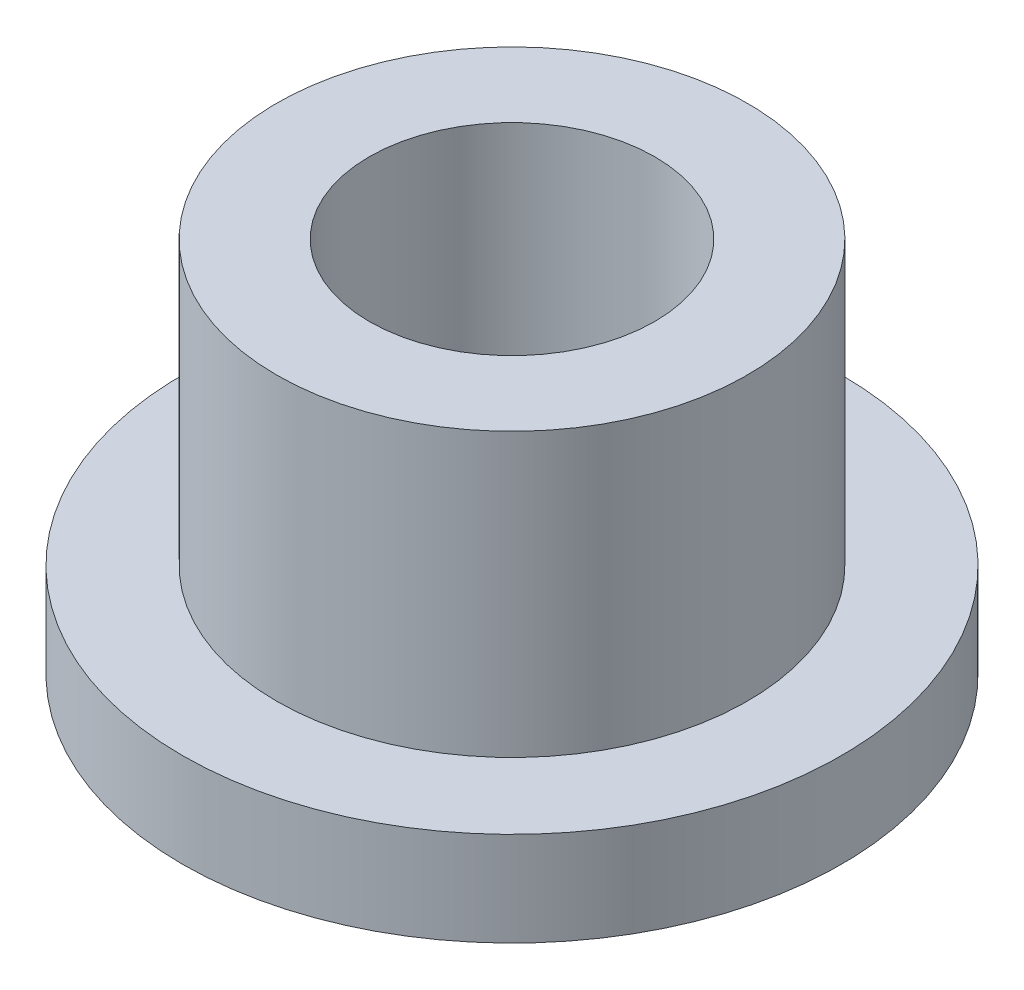
from build123d import *

# Parameters (mm, degrees)
SKETCH2_R           = 7.9375
SKETCH2_R_2         = 4.8133
BOSS_EXTRUDE1_DEPTH = 12.7
SKETCH3_R           = 11.1125
SKETCH3_R_2         = 7.9375
BOSS_EXTRUDE2_DEPTH = 3.175


with BuildPart() as part:
    # Sketch2 → Boss-Extrude1 (new body)
    with BuildSketch(Plane(origin=(0, 0, 0), x_dir=(1, 0, 0), z_dir=(0, 1, 0))):
        Circle(SKETCH2_R)
        Circle(SKETCH2_R_2, mode=Mode.SUBTRACT)
    extrude(amount=BOSS_EXTRUDE1_DEPTH)

    # Sketch3 → Boss-Extrude2 (add)
    with BuildSketch(Plane(origin=(0, 0, 0), x_dir=(1, 0, 0), z_dir=(0, 1, 0))):
        Circle(SKETCH3_R)
        Circle(SKETCH3_R_2, mode=Mode.SUBTRACT)
    extrude(amount=BOSS_EXTRUDE2_DEPTH)


solid = part.part
